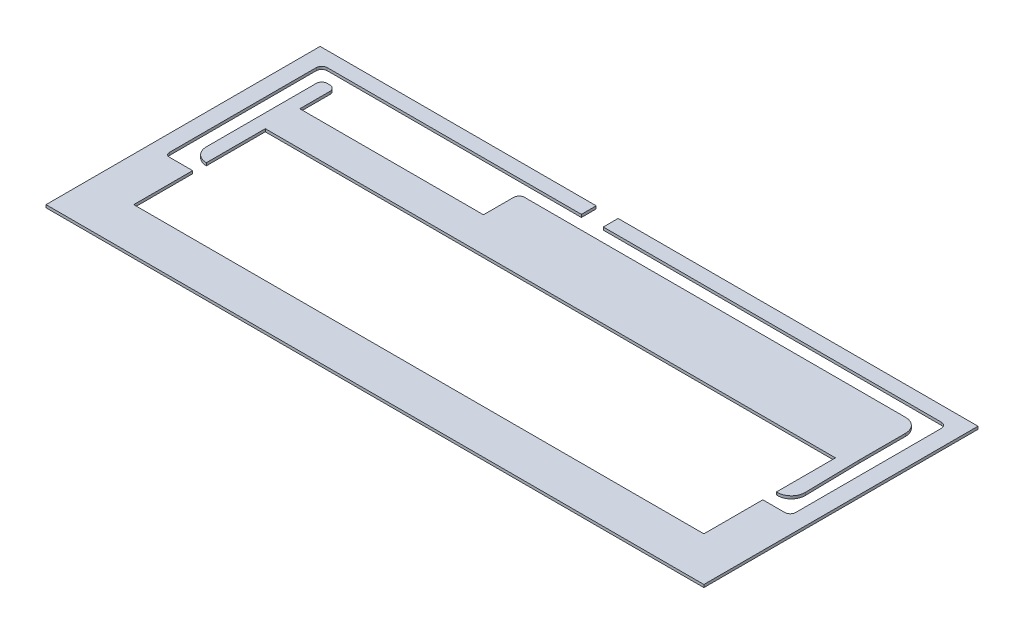
from build123d import *

# Parameters (mm, degrees)
CROQUIS1_W              = 486.2
CROQUIS1_H              = 206.2
CROQUIS1_W_2            = 480
CROQUIS1_H_2            = 200
SALIENTE_EXTRUIR1_DEPTH = 12
CROQUIS3_W              = 486.2
CROQUIS3_H              = 206.2
CROQUIS3_W_2            = 480
CROQUIS3_H_2            = 200
CORTAR_EXTRUIR1_DEPTH   = 5
CORTAR_EXTRUIR3_DEPTH   = 8
CROQUIS4_W              = 20
CROQUIS4_H              = 6
CORTAR_EXTRUIR4_DEPTH   = 3
CORTAR_EXTRUIR5_DEPTH   = 2
CROQUIS7_W              = 721.947089947
CROQUIS7_H              = 359.419856831
CORTAR_EXTRUIR6_DEPTH   = 10
CROQUIS8_W              = 416
CROQUIS8_H              = 96
CORTAR_EXTRUIR7_DEPTH   = 10
CROQUIS9_W              = 531.904745737
CROQUIS9_H              = 246.353411826
CORTAR_EXTRUIR9_DEPTH   = 10
CROQUIS10_W             = 531.904745737
CROQUIS10_H             = 246.353411826
CORTAR_EXTRUIR10_DEPTH  = 10


with BuildPart() as part:
    # Croquis1 → Saliente-Extruir1 (new body)
    with BuildSketch(Plane(origin=(0, 0, 0), x_dir=(1, 0, 0), z_dir=(0, 1, 0))):
        with Locations((240, 100)):
            Rectangle(CROQUIS1_W, CROQUIS1_H)
        with Locations((240, 100)):
            Rectangle(CROQUIS1_W_2, CROQUIS1_H_2, mode=Mode.SUBTRACT)
        with Locations((240, 100)):
            Rectangle(CROQUIS1_W_2, CROQUIS1_H_2)
    extrude(amount=SALIENTE_EXTRUIR1_DEPTH)

    # Croquis3 → Cortar-Extruir1 (cut)
    with BuildSketch(Plane(origin=(0, 12, 0), x_dir=(1, 0, 0), z_dir=(0, 1, 0))):
        with Locations((240, 100)):
            Rectangle(CROQUIS3_W, CROQUIS3_H)
        with Locations((240, 100)):
            Rectangle(CROQUIS3_W_2, CROQUIS3_H_2, mode=Mode.SUBTRACT)
    extrude(amount=-CORTAR_EXTRUIR1_DEPTH, mode=Mode.SUBTRACT)

    # Croquis2 → Cortar-Extruir3 (cut)
    with BuildSketch(Plane(origin=(0, 12, 0), x_dir=(1, 0, 0), z_dir=(0, 1, 0))):
        with BuildLine():
            ThreePointArc((16, 189.1902066), (13.171572875, 188.018633725), (12, 185.1902066))
            Line((12, 185.1902066), (12, 78))
            ThreePointArc((12, 78), (12.878679656, 75.878679656), (15, 75))
            Line((15, 75), (32, 75))
            Line((32, 75), (32, 32))
            Line((32, 32), (448, 32))
            Line((448, 32), (448, 75))
            Line((448, 75), (464, 75))
            ThreePointArc((464, 75), (466.828427125, 76.171572875), (468, 79))
            Line((468, 79), (468, 185.1902066))
            ThreePointArc((468, 185.1902066), (466.828427125, 188.018633725), (464, 189.1902066))
            Line((464, 189.1902066), (217.424703227, 189.1902066))
            Line((217.424703227, 189.1902066), (217.424703227, 203.1))
            Line((217.424703227, 203.1), (201.44869327, 203.1))
            Line((201.44869327, 203.1), (201.44869327, 189.1902066))
            Line((201.44869327, 189.1902066), (16, 189.1902066))
        make_face()
        with BuildLine():
            Line((32, 85), (31.963588191, 85))
            ThreePointArc((31.963588191, 85), (24.892520379, 87.928932188), (21.963588191, 95))
            Line((21.963588191, 95), (21.963588191, 175.1902066))
            ThreePointArc((21.963588191, 175.1902066), (23.135161066, 178.018633725), (25.963588191, 179.1902066))
            Line((25.963588191, 179.1902066), (28, 179.1902066))
            ThreePointArc((28, 179.1902066), (30.828427125, 178.018633725), (32, 175.1902066))
            Line((32, 175.1902066), (32, 153.1902066))
            Line((32, 153.1902066), (166, 153.1902066))
            Line((166, 153.1902066), (166, 175.1902066))
            ThreePointArc((166, 175.1902066), (167.171572875, 178.018633725), (170, 179.1902066))
            Line((170, 179.1902066), (448.036411809, 179.1902066))
            ThreePointArc((448.036411809, 179.1902066), (455.107479621, 176.261274412), (458.036411809, 169.1902066))
            Line((458.036411809, 169.1902066), (458.036411809, 135.000000034))
            Line((458.036411809, 135.000000034), (458.803569043, 95.19268186))
            ThreePointArc((458.803569043, 95.19268186), (455.944291637, 87.997386866), (448.80542553, 85))
            Line((448.80542553, 85), (448, 85))
            Line((448, 85), (448, 128))
            Line((448, 128), (32, 128))
            Line((32, 128), (32, 85))
        make_face(mode=Mode.SUBTRACT)
    extrude(amount=-CORTAR_EXTRUIR3_DEPTH, mode=Mode.SUBTRACT)

    # Croquis4 → Cortar-Extruir4 (cut)
    with BuildSketch(Plane(origin=(0, 12, 0), x_dir=(1, 0, 0), z_dir=(0, 1, 0))):
        with BuildLine():
            Line((31.963588191, 85), (32, 128))
            Line((32, 128), (32, 134))
            Line((32, 134), (32, 147.1902066))
            Line((32, 147.1902066), (32, 153.1902066))
            Line((32, 153.1902066), (32, 175.1902066))
            ThreePointArc((32, 175.1902066), (30.828427125, 178.018633725), (28, 179.1902066))
            Line((28, 179.1902066), (25.963588191, 179.1902066))
            ThreePointArc((25.963588191, 179.1902066), (23.135161066, 178.018633725), (21.963588191, 175.1902066))
            Line((21.963588191, 175.1902066), (21.963588191, 95))
            ThreePointArc((21.963588191, 95), (24.892520379, 87.928932188), (31.963588191, 85))
        make_face()
        with Locations((42, 131)):
            Rectangle(CROQUIS4_W, CROQUIS4_H)
        with Locations((42, 150.1902066)):
            Rectangle(CROQUIS4_W, CROQUIS4_H)
        with BuildLine():
            ThreePointArc((12, 78), (12.878679656, 75.878679656), (15, 75))
            Line((15, 75), (32, 75))
            Line((32, 75), (32, 69))
            Line((32, 69), (6, 69))
            Line((6, 69), (6, 80))
            Line((6, 80), (6, 195.1902066))
            Line((6, 195.1902066), (16, 195.1902066))
            Line((16, 195.1902066), (32, 195.1902066))
            Line((32, 195.1902066), (32, 189.1902066))
            Line((32, 189.1902066), (16, 189.1902066))
            ThreePointArc((16, 189.1902066), (13.171572875, 188.018633725), (12, 185.1902066))
            Line((12, 185.1902066), (12, 80))
            Line((12, 80), (12, 78))
        make_face()
        with Locations((42, 192.1902066)):
            Rectangle(CROQUIS4_W, CROQUIS4_H)
        with Locations((42, 29)):
            Rectangle(CROQUIS4_W, CROQUIS4_H)
        with Locations((156, 192.1902066)):
            Rectangle(CROQUIS4_W, CROQUIS4_H)
        with Locations((156, 150.1902066)):
            Rectangle(CROQUIS4_W, CROQUIS4_H)
        with BuildLine():
            Line((166, 147.1902066), (448, 147.1902066))
            Line((448, 147.1902066), (458.036411809, 147.1902066))
            Line((458.036411809, 147.1902066), (458.036411809, 169.1902066))
            ThreePointArc((458.036411809, 169.1902066), (455.107479621, 176.261274412), (448.036411809, 179.1902066))
            Line((448.036411809, 179.1902066), (170, 179.1902066))
            ThreePointArc((170, 179.1902066), (167.171572875, 178.018633725), (166, 175.1902066))
            Line((166, 175.1902066), (166, 153.1902066))
            Line((166, 153.1902066), (166, 147.1902066))
        make_face()
        with BuildLine():
            Line((458.036411809, 169.1902066), (458.036411809, 147.1902066))
            Line((458.036411809, 147.1902066), (474, 147.1902066))
            Line((474, 147.1902066), (474, 195.1902066))
            Line((474, 195.1902066), (166, 195.1902066))
            Line((166, 195.1902066), (166, 189.1902066))
            Line((166, 189.1902066), (166, 175.1902066))
            ThreePointArc((166, 175.1902066), (167.171572875, 178.018633725), (170, 179.1902066))
            Line((170, 179.1902066), (448.036411809, 179.1902066))
            ThreePointArc((448.036411809, 179.1902066), (455.107479621, 176.261274412), (458.036411809, 169.1902066))
        make_face()
        with BuildLine():
            Line((448.80542553, 85), (448, 85))
            Line((448, 85), (448, 69))
            Line((448, 69), (474, 69))
            Line((474, 69), (474, 147.1902066))
            Line((474, 147.1902066), (458.036411809, 147.1902066))
            Line((458.036411809, 147.1902066), (458.036411809, 135.000000034))
            Line((458.036411809, 135.000000034), (458.803569043, 95.19268186))
            ThreePointArc((458.803569043, 95.19268186), (455.944291637, 87.997386866), (448.80542553, 85))
        make_face()
        with Locations((438, 131)):
            Rectangle(CROQUIS4_W, CROQUIS4_H)
        with Locations((438, 29)):
            Rectangle(CROQUIS4_W, CROQUIS4_H)
        with BuildLine():
            Line((448, 134), (448, 128))
            Line((448, 128), (448, 85))
            Line((448, 85), (448.80542553, 85))
            ThreePointArc((448.80542553, 85), (455.944291637, 87.997386866), (458.803569043, 95.19268186))
            Line((458.803569043, 95.19268186), (458.036411809, 135.000000034))
            Line((458.036411809, 135.000000034), (458.036411809, 147.1902066))
            Line((458.036411809, 147.1902066), (448, 147.1902066))
            Line((448, 147.1902066), (448, 134))
        make_face()
    extrude(amount=-CORTAR_EXTRUIR4_DEPTH, mode=Mode.SUBTRACT)

    # Croquis5 → Cortar-Extruir5 (cut)
    with BuildSketch(Plane(origin=(0, 4, 0), x_dir=(1, 0, 0), z_dir=(0, 1, 0))):
        with BuildLine():
            Line((32.046028397, 84.926485337), (32, 75))
            Line((32, 75), (15, 75))
            ThreePointArc((15, 75), (12.878679656, 75.878679656), (12, 78))
            Line((12, 78), (12, 185.1902066))
            ThreePointArc((12, 185.1902066), (13.171572875, 188.018633725), (16, 189.1902066))
            Line((16, 189.1902066), (201.44869327, 189.1902066))
            Line((201.44869327, 189.1902066), (201.44869327, 203.1))
            Line((201.44869327, 203.1), (217.424703227, 203.1))
            Line((217.424703227, 203.1), (217.424703227, 189.1902066))
            Line((217.424703227, 189.1902066), (464, 189.1902066))
            ThreePointArc((464, 189.1902066), (466.828427125, 188.018633725), (468, 185.1902066))
            Line((468, 185.1902066), (468, 79))
            ThreePointArc((468, 79), (466.828427125, 76.171572875), (464, 75))
            Line((464, 75), (448, 75))
            Line((448, 75), (448, 85))
            Line((448, 85), (448.80542553, 85))
            ThreePointArc((448.80542553, 85), (455.917657262, 88.023512896), (458.803569043, 95.19268186))
            Line((458.803569043, 95.19268186), (458.036411809, 169.1902066))
            ThreePointArc((458.036411809, 169.1902066), (455.107479621, 176.261274412), (448.036411809, 179.1902066))
            Line((448.036411809, 179.1902066), (170, 179.1902066))
            ThreePointArc((170, 179.1902066), (167.171572875, 178.018633725), (166, 175.1902066))
            Line((166, 175.1902066), (166, 153.1902066))
            Line((166, 153.1902066), (32, 153.1902066))
            Line((32, 153.1902066), (32, 175.1902066))
            ThreePointArc((32, 175.1902066), (30.828427125, 178.018633725), (28, 179.1902066))
            Line((28, 179.1902066), (25.963588191, 179.1902066))
            ThreePointArc((25.963588191, 179.1902066), (23.135161066, 178.018633725), (21.963588191, 175.1902066))
            Line((21.963588191, 175.1902066), (21.963588191, 95))
            ThreePointArc((21.963588191, 95), (24.91720844, 87.873793117), (32.046028397, 84.926485337))
        make_face()
    extrude(amount=-CORTAR_EXTRUIR5_DEPTH, mode=Mode.SUBTRACT)

    # Croquis7 → Cortar-Extruir6 (cut)
    with BuildSketch(Plane(origin=(0, 2, 0), x_dir=(1, 0, 0), z_dir=(0, 1, 0))):
        with Locations((149.368191722, 161.470369199)):
            Rectangle(CROQUIS7_W, CROQUIS7_H)
    extrude(amount=-CORTAR_EXTRUIR6_DEPTH, mode=Mode.SUBTRACT)

    # Croquis8 → Cortar-Extruir7 (cut)
    with BuildSketch(Plane(origin=(0, 4, 0), x_dir=(1, 0, 0), z_dir=(0, 1, 0))):
        with Locations((240, 80)):
            Rectangle(CROQUIS8_W, CROQUIS8_H)
    extrude(amount=-CORTAR_EXTRUIR7_DEPTH, mode=Mode.SUBTRACT)


with BuildPart() as cortar_extruir7_piece_1:
    # of the separate pieces the step leaves, piece 1, a body of its own (cortar_extruir7_pieces)
    add(part.part.solids().sort_by_distance((483.1, 2, 3.1))[0])


with BuildPart() as cortar_extruir7_piece_2:
    # of the separate pieces the step leaves, piece 2, a body of its own (cortar_extruir7_pieces)
    add(part.part.solids().sort_by_distance((32, 2, -128))[0])


with BuildPart() as cortar_extruir9_tool:
    # Croquis9 → Cortar-Extruir9 (new body)
    with BuildSketch(Plane(origin=(0, 9, 0), x_dir=(1, 0, 0), z_dir=(0, 1, 0))):
        with Locations((247.004349215, 106.418772052)):
            Rectangle(CROQUIS9_W, CROQUIS9_H)
    extrude(amount=CORTAR_EXTRUIR9_DEPTH)


with BuildPart() as cortar_extruir7_piece_1_1:
    add(cortar_extruir7_piece_1.part)

    # Cortar-Extruir9: cut by cortar_extruir9_tool
    add(cortar_extruir9_tool.part, mode=Mode.SUBTRACT)


with BuildPart() as cortar_extruir7_piece_2_1:
    add(cortar_extruir7_piece_2.part)

    # Cortar-Extruir9: cut by cortar_extruir9_tool
    add(cortar_extruir9_tool.part, mode=Mode.SUBTRACT)


with BuildPart() as cortar_extruir10_tool:
    # Croquis10 → Cortar-Extruir10 (new body)
    with BuildSketch(Plane(origin=(0, 7, 0), x_dir=(1, 0, 0), z_dir=(0, 1, 0))):
        with Locations((247.004349215, 106.418772052)):
            Rectangle(CROQUIS10_W, CROQUIS10_H)
    extrude(amount=-CORTAR_EXTRUIR10_DEPTH)


with BuildPart() as cortar_extruir7_piece_1_2:
    add(cortar_extruir7_piece_1_1.part)

    # Cortar-Extruir10: cut by cortar_extruir10_tool
    add(cortar_extruir10_tool.part, mode=Mode.SUBTRACT)


with BuildPart() as cortar_extruir7_piece_2_2:
    add(cortar_extruir7_piece_2_1.part)

    # Cortar-Extruir10: cut by cortar_extruir10_tool
    add(cortar_extruir10_tool.part, mode=Mode.SUBTRACT)


solid = Compound([cortar_extruir7_piece_1_2.part, cortar_extruir7_piece_2_2.part])
